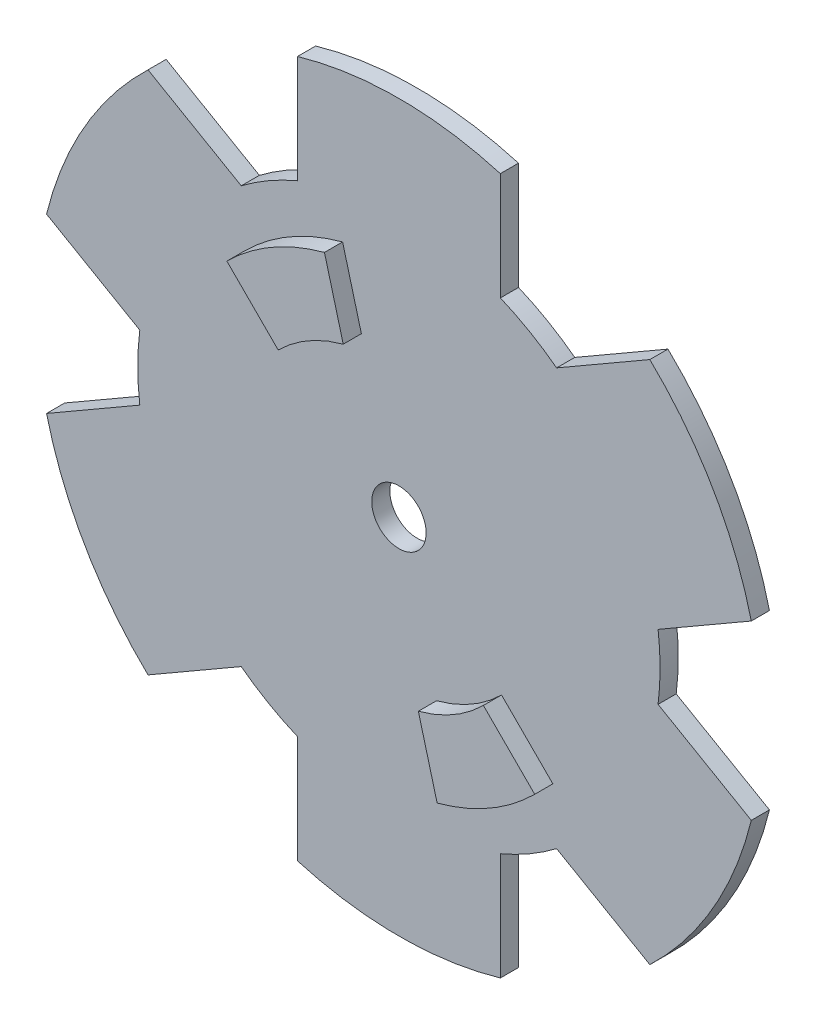
from build123d import *

# Parameters (mm, degrees)
EXTRUDE1_DEPTH      = 1.5875
SKETCH2_R           = 2.38125
CUT_EXTRUDE1_DEPTH  = 2.5875
BOSS_EXTRUDE1_DEPTH = 1.5875


with BuildPart() as part:
    # Sketch1 → Extrude1 (new body)
    with BuildSketch(Plane.XY):
        with BuildLine():
            Line((22.679380466, 2.841623674), (30.838674439, 7.552394246))
            ThreePointArc((30.838674439, 7.552394246), (27.49630657, 15.875), (21.959902496, 22.93087836))
            Line((21.959902496, 22.93087836), (13.800608523, 18.220107788))
            ThreePointArc((13.800608523, 18.220107788), (11.428354249, 19.794490207), (8.878771943, 21.061731462))
            Line((8.878771943, 21.061731462), (8.878771943, 30.483272606))
            ThreePointArc((8.878771943, 30.483272606), (0, 31.75), (-8.878771943, 30.483272606))
            Line((-8.878771943, 30.483272606), (-8.878771943, 21.061731462))
            ThreePointArc((-8.878771943, 21.061731462), (-11.42835425, 19.794490207), (-13.800608523, 18.220107788))
            Line((-13.800608523, 18.220107788), (-21.959902496, 22.93087836))
            ThreePointArc((-21.959902496, 22.93087836), (-27.49630657, 15.875), (-30.838674439, 7.552394246))
            Line((-30.838674439, 7.552394246), (-22.679380466, 2.841623674))
            ThreePointArc((-22.679380466, 2.841623674), (-22.856708499, 0), (-22.679380466, -2.841623674))
            Line((-22.679380466, -2.841623674), (-30.838674439, -7.552394246))
            ThreePointArc((-30.838674439, -7.552394246), (-27.49630657, -15.875), (-21.959902496, -22.93087836))
            Line((-21.959902496, -22.93087836), (-13.800608523, -18.220107788))
            ThreePointArc((-13.800608523, -18.220107788), (-11.428354249, -19.794490207), (-8.878771943, -21.061731462))
            Line((-8.878771943, -21.061731462), (-8.878771943, -30.483272606))
            ThreePointArc((-8.878771943, -30.483272606), (0, -31.75), (8.878771943, -30.483272606))
            Line((8.878771943, -30.483272606), (8.878771943, -21.061731462))
            ThreePointArc((8.878771943, -21.061731462), (11.42835425, -19.794490207), (13.800608523, -18.220107788))
            Line((13.800608523, -18.220107788), (21.959902496, -22.93087836))
            ThreePointArc((21.959902496, -22.93087836), (27.49630657, -15.875), (30.838674439, -7.552394246))
            Line((30.838674439, -7.552394246), (22.679380466, -2.841623674))
            ThreePointArc((22.679380466, -2.841623674), (22.856708499, 0), (22.679380466, 2.841623674))
        make_face()
    extrude(amount=EXTRUDE1_DEPTH)

    # Sketch2 → Cut-Extrude1 (cut, through all)
    with BuildSketch(Plane.XY.offset(1.5875)):
        Circle(SKETCH2_R)
    extrude(amount=-CUT_EXTRUDE1_DEPTH, mode=Mode.SUBTRACT)

    # Sketch3 → Boss-Extrude1 (add)
    with BuildSketch(Plane.XY.offset(1.5875)):
        with BuildLine():
            Line((-13.470384182, 13.470384182), (-8.980256121, 8.980256121))
            ThreePointArc((-8.980256121, 8.980256121), (-6.35, 10.998522628), (-3.287001873, 12.267257994))
            Line((-3.287001873, 12.267257994), (-4.930502809, 18.400886991))
            ThreePointArc((-4.930502809, 18.400886991), (-9.525, 16.497783942), (-13.470384182, 13.470384182))
        make_face()
        with BuildLine():
            Line((13.470384182, -13.470384182), (8.980256121, -8.980256121))
            ThreePointArc((8.980256121, -8.980256121), (6.35, -10.998522628), (3.287001873, -12.267257994))
            Line((3.287001873, -12.267257994), (4.930502809, -18.400886991))
            ThreePointArc((4.930502809, -18.400886991), (9.525, -16.497783942), (13.470384182, -13.470384182))
        make_face()
    extrude(amount=BOSS_EXTRUDE1_DEPTH)


solid = part.part
